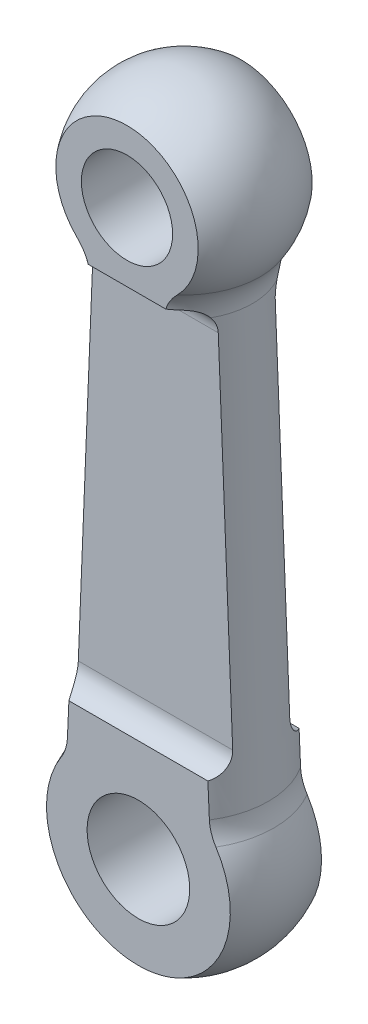
from build123d import *

# Parameters (mm, degrees)
SKETCH2_R               = 2
SKETCH2_R_2             = 2.25
CUT_EXTRUDE1_DEPTH      = 5.5
CUT_EXTRUDE1_DEPTH_BACK = 5.5
SKETCH3_OUTSIDE_W       = 16.912
SKETCH3_OUTSIDE_H       = 42.61
CUT_EXTRUDE2_DEPTH      = 5.5
CUT_EXTRUDE2_DEPTH_BACK = 5.5


with BuildPart() as part:
    # Sketch1 → Revolve1 (revolve)
    with BuildSketch(Plane.XY, mode=Mode.PRIVATE) as revolve1_sk:
        with BuildLine():
            Line((0, 29), (0, -4.5))
            ThreePointArc((0, -4.5), (3.872392662, -2.292285993), (3.945169537, 2.1646333))
            ThreePointArc((3.945169537, 2.1646333), (3.770913113, 2.59367544), (3.7, 3.051292953))
            Line((3.7, 3.051292953), (3, 21.605833201))
            ThreePointArc((3, 21.605833201), (3.073295416, 22.222791768), (3.33238548, 22.787488528))
            ThreePointArc((3.33238548, 22.787488528), (3.524914601, 26.890760973), (0, 29))
        make_face()
    revolve(revolve1_sk.sketch.rotate(Axis((0, 0, 0), (0, 1, 0)), 90), axis=Axis((0, 0, 0), (0, 1, 0)))  # turned: the seam where the file's is

    # Sketch2 → Cut-Extrude1 (cut, two sides)
    with BuildSketch(Plane.XY) as cut_extrude1_sk:
        with Locations((0, 25)):
            Circle(SKETCH2_R)
        with Locations(Location((0, 0, 0), (0, 0, 74.166628888))):  # turned: the seam where the file's is
            Circle(SKETCH2_R_2)
    extrude(amount=CUT_EXTRUDE1_DEPTH, mode=Mode.SUBTRACT)
    extrude(cut_extrude1_sk.sketch, amount=-CUT_EXTRUDE1_DEPTH_BACK, mode=Mode.SUBTRACT)

    # Sketch3 outside → Cut-Extrude2 (cut, two sides)
    with BuildSketch(Plane(origin=(0, 0, 0), x_dir=(0, 0, -1), z_dir=(1, 0, 0))) as cut_extrude2_sk:
        with Locations((0, 12.25)):
            Rectangle(SKETCH3_OUTSIDE_W, SKETCH3_OUTSIDE_H)
        with BuildLine():
            Line((-2.5, 29), (2.5, 29))
            Line((2.5, 29), (2.5, 22))
            Line((2.5, 22), (2.25, 22))
            ThreePointArc((2.25, 22), (1.542893219, 21.707106781), (1.25, 21))
            Line((1.25, 21), (1.25, 5.468245837))
            ThreePointArc((1.25, 5.468245837), (1.459430585, 4.855873401), (2, 4.5))
            Line((2, 4.5), (2, -5))
            Line((2, -5), (-2, -5))
            Line((-2, -5), (-2, 4.5))
            ThreePointArc((-2, 4.5), (-1.459430585, 4.855873401), (-1.25, 5.468245837))
            Line((-1.25, 5.468245837), (-1.25, 21))
            ThreePointArc((-1.25, 21), (-1.542893219, 21.707106781), (-2.25, 22))
            Line((-2.25, 22), (-2.5, 22))
            Line((-2.5, 22), (-2.5, 29))
        make_face(mode=Mode.SUBTRACT)
    extrude(amount=CUT_EXTRUDE2_DEPTH, mode=Mode.SUBTRACT)
    extrude(cut_extrude2_sk.sketch, amount=-CUT_EXTRUDE2_DEPTH_BACK, mode=Mode.SUBTRACT)


solid = part.part
